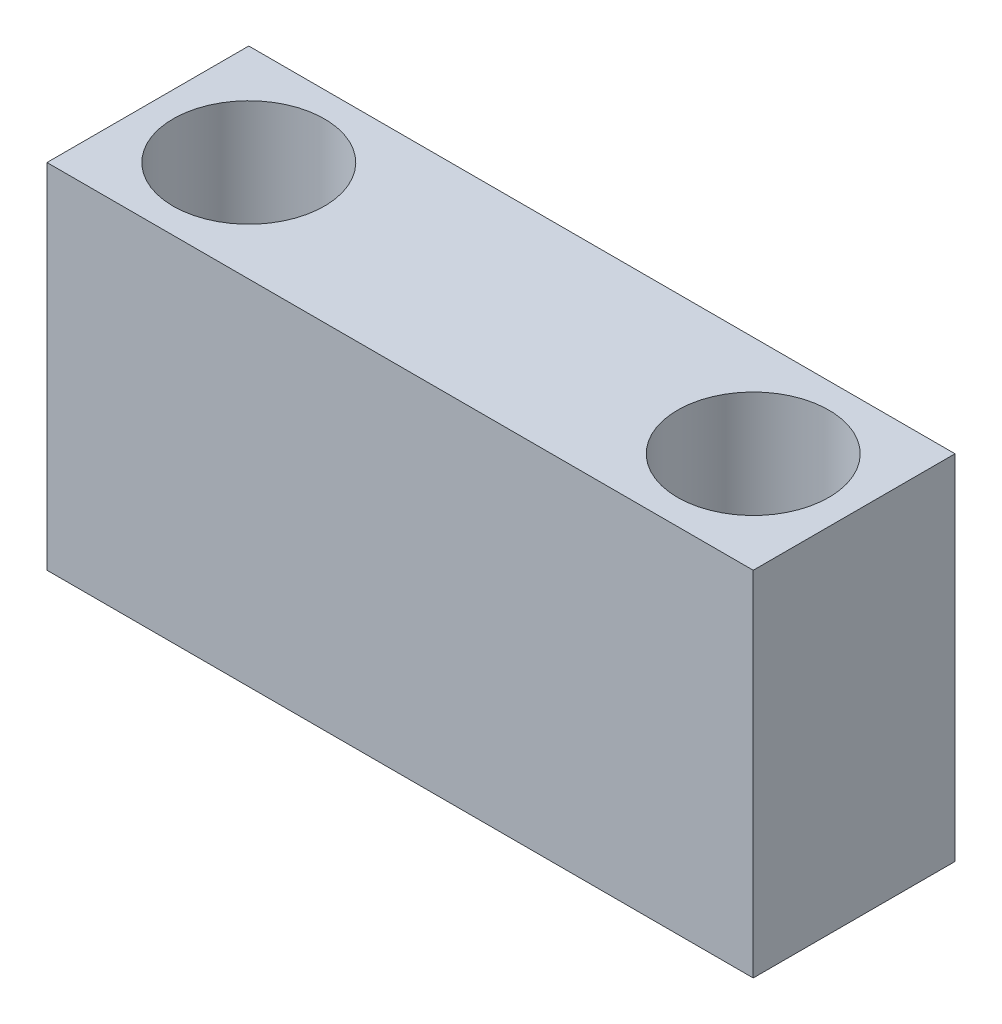
from build123d import *

# Parameters (mm, degrees)
SKETCH_1_W                = 70
SKETCH_1_H                = 35
EXTRUDE_1_DEPTH           = 10
HOLE_WIZARD_1_D           = 9
HOLE_WIZARD_1_CBORE_D     = 15
HOLE_WIZARD_1_CBORE_DEPTH = 12


with BuildPart() as part:
    # 草图1 → 凸台-拉伸1 (new body, symmetric)
    with BuildSketch(Plane.XY):
        Rectangle(SKETCH_1_W, SKETCH_1_H)
    extrude(amount=EXTRUDE_1_DEPTH, both=True)

    # 打孔尺寸(%根据)内六角圆柱头螺钉的类型1 (through all)
    with Locations(Plane(origin=(-25, 17.5, 0), x_dir=(0, 0, 1), z_dir=(0, 1, 0))):
        with Locations((0, 0), (0, 50)):
            CounterBoreHole(HOLE_WIZARD_1_D / 2, HOLE_WIZARD_1_CBORE_D / 2, HOLE_WIZARD_1_CBORE_DEPTH)


solid = part.part
